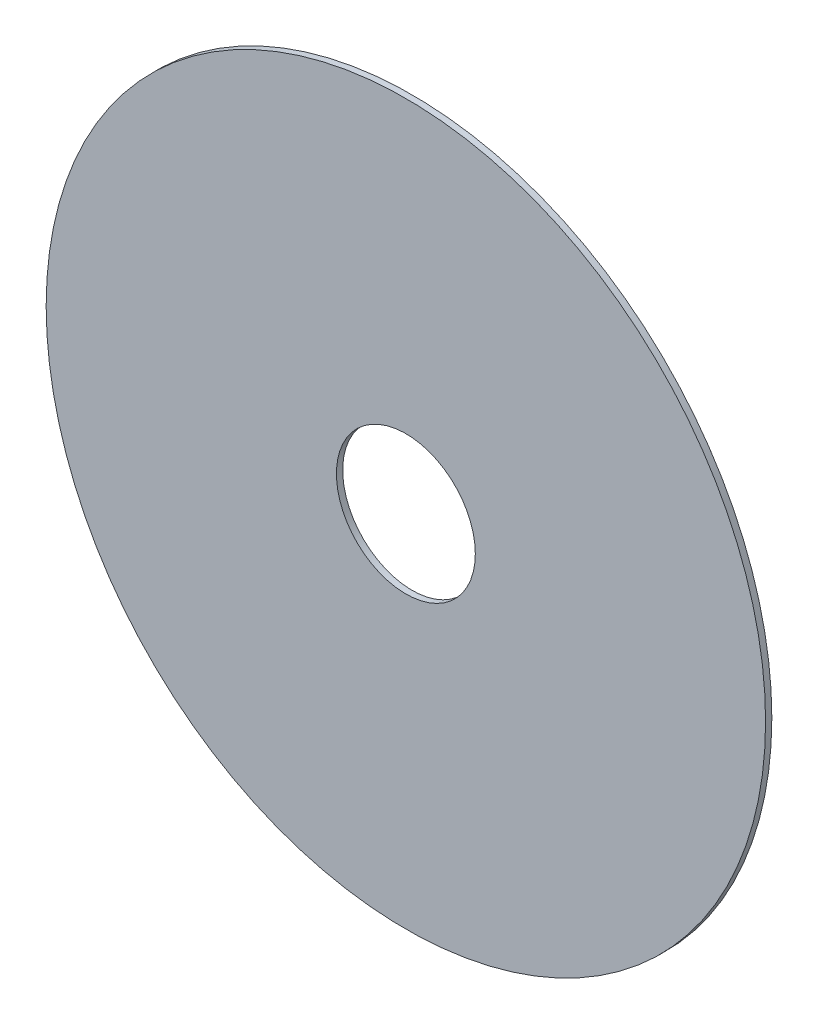
from build123d import *

# Parameters (mm, degrees)
SZKIC2_R                    = 57.5
SZKIC2_R_2                  = 11.1
DODANIE_WYCI_GNI_CIE1_DEPTH = 1


with BuildPart() as part:
    # Szkic2 → Dodanie-wyciągnięcie1 (new body)
    with BuildSketch(Plane.XY):
        Circle(SZKIC2_R)
        Circle(SZKIC2_R_2, mode=Mode.SUBTRACT)
    extrude(amount=DODANIE_WYCI_GNI_CIE1_DEPTH)


solid = part.part
